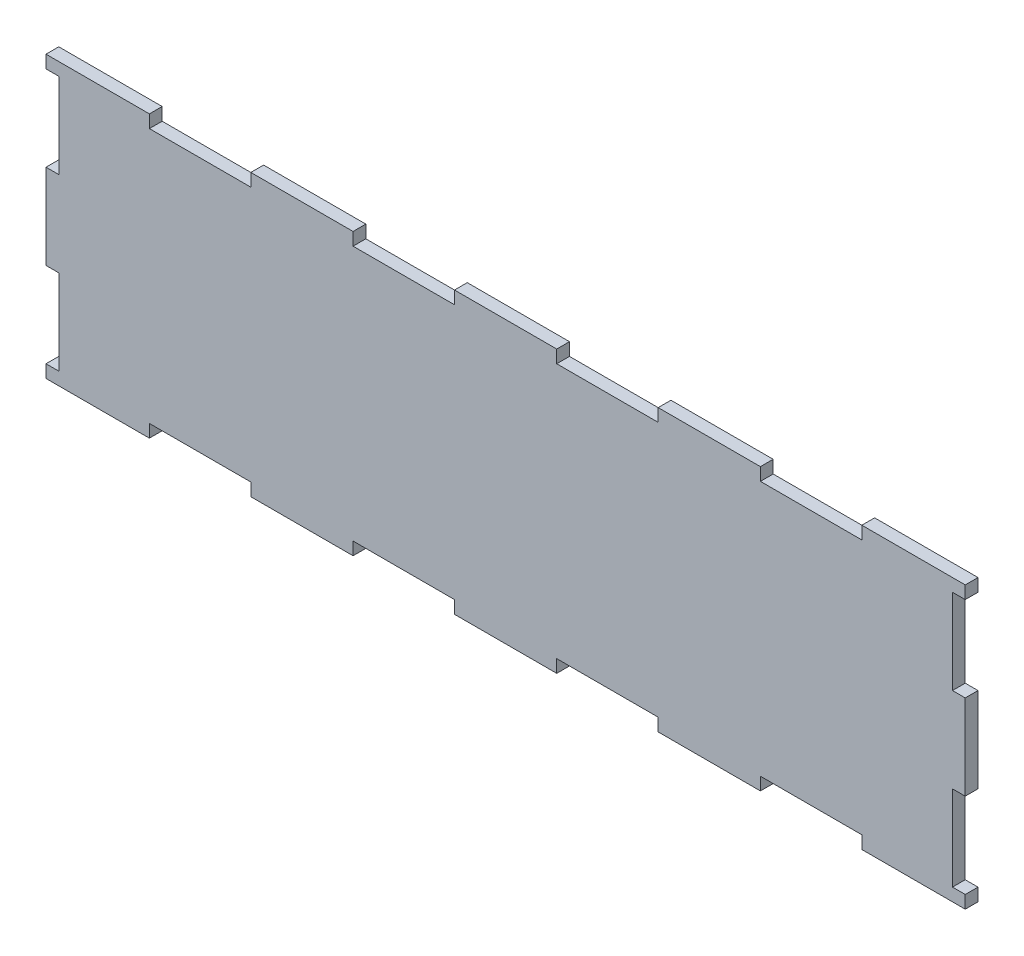
from build123d import *

# Parameters (mm, degrees)
BOSS_EXTRUDE1_DEPTH = 3


with BuildPart() as part:
    # Sketch1 → Boss-Extrude1 (new body)
    with BuildSketch(Plane.XY):
        Polygon((-83.694098756, 3), (-107.98916098, 3), (-107.98916098, 6), (-104.98916098, 6), (-104.98916098, 26), (-107.98916098, 26), (-107.98916098, 46), (-104.98916098, 46), (-104.98916098, 66), (-107.98916098, 66), (-107.98916098, 69), (-83.694098756, 69), (-83.694098756, 66), (-59.857888398, 66), (-59.857888398, 69), (-35.836210357, 69), (-35.836210357, 66), (-12, 66), (-12, 69), (12.021678041, 69), (12.021678041, 66), (35.857888398, 66), (35.857888398, 69), (59.879566439, 69), (59.879566439, 66), (83.715776796, 66), (83.715776796, 69), (108.01083902, 69), (108.01083902, 66), (105.01083902, 66), (105.01083902, 46), (108.01083902, 46), (108.01083902, 26), (105.01083902, 26), (105.01083902, 6), (108.01083902, 6), (108.01083902, 3), (83.715776796, 3), (83.715776796, 6), (59.879566439, 6), (59.879566439, 3), (35.857888398, 3), (35.857888398, 6), (12.021678041, 6), (12.021678041, 3), (-12, 3), (-12, 6), (-35.836210357, 6), (-35.836210357, 3), (-59.857888398, 3), (-59.857888398, 6), (-83.694098756, 6), align=None)
    extrude(amount=BOSS_EXTRUDE1_DEPTH)


solid = part.part
